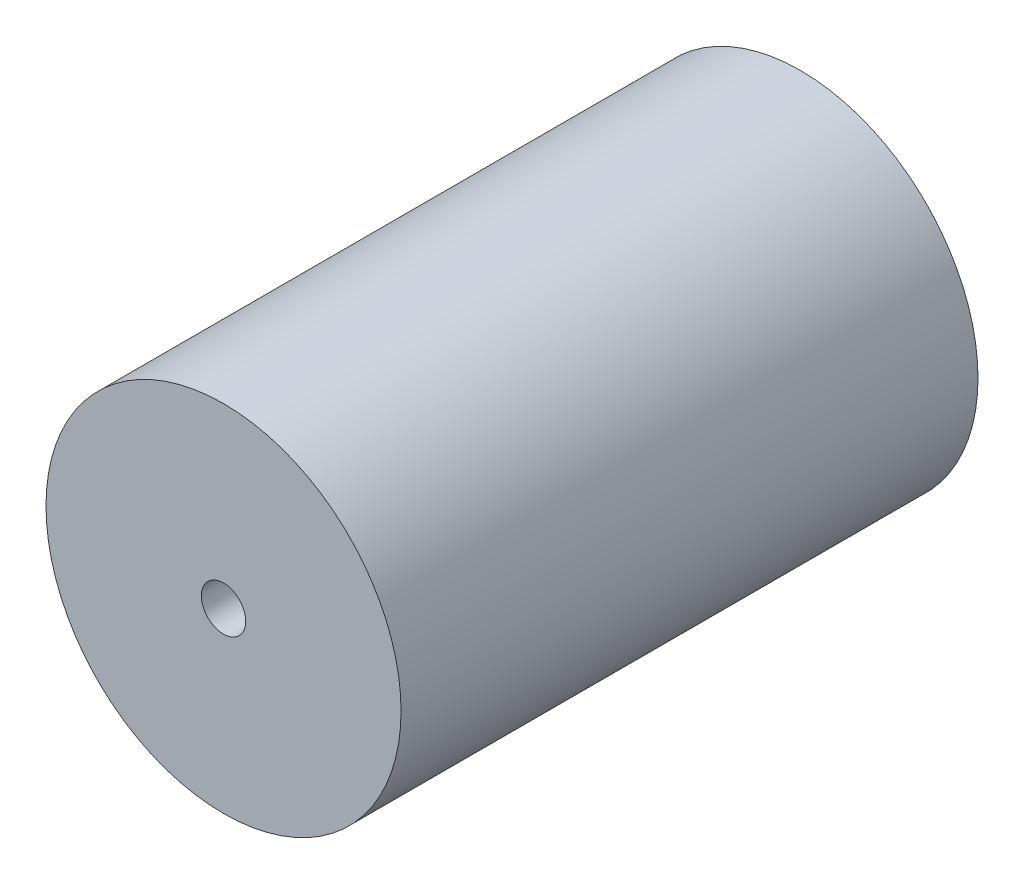
from build123d import *

# Parameters (mm, degrees)
SKETCH1_R           = 4
SKETCH1_R_2         = 2.6
BOSS_EXTRUDE3_DEPTH = 11
SKETCH3_R           = 4
BOSS_EXTRUDE4_DEPTH = 2
SKETCH4_R           = 0.5
CUT_EXTRUDE1_DEPTH  = 1


with BuildPart() as part:
    # Sketch1 → Boss-Extrude3 (new body)
    with BuildSketch(Plane.XY):
        Circle(SKETCH1_R)
        Circle(SKETCH1_R_2, mode=Mode.SUBTRACT)
    extrude(amount=BOSS_EXTRUDE3_DEPTH)

    # Sketch3 → Boss-Extrude4 (add)
    with BuildSketch(Plane.XY.offset(11)):
        Circle(SKETCH3_R)
    extrude(amount=BOSS_EXTRUDE4_DEPTH)

    # Sketch4 → Cut-Extrude1 (cut)
    with BuildSketch(Plane.XY.offset(13)):
        Circle(SKETCH4_R)
    extrude(amount=-CUT_EXTRUDE1_DEPTH, mode=Mode.SUBTRACT)


solid = part.part
